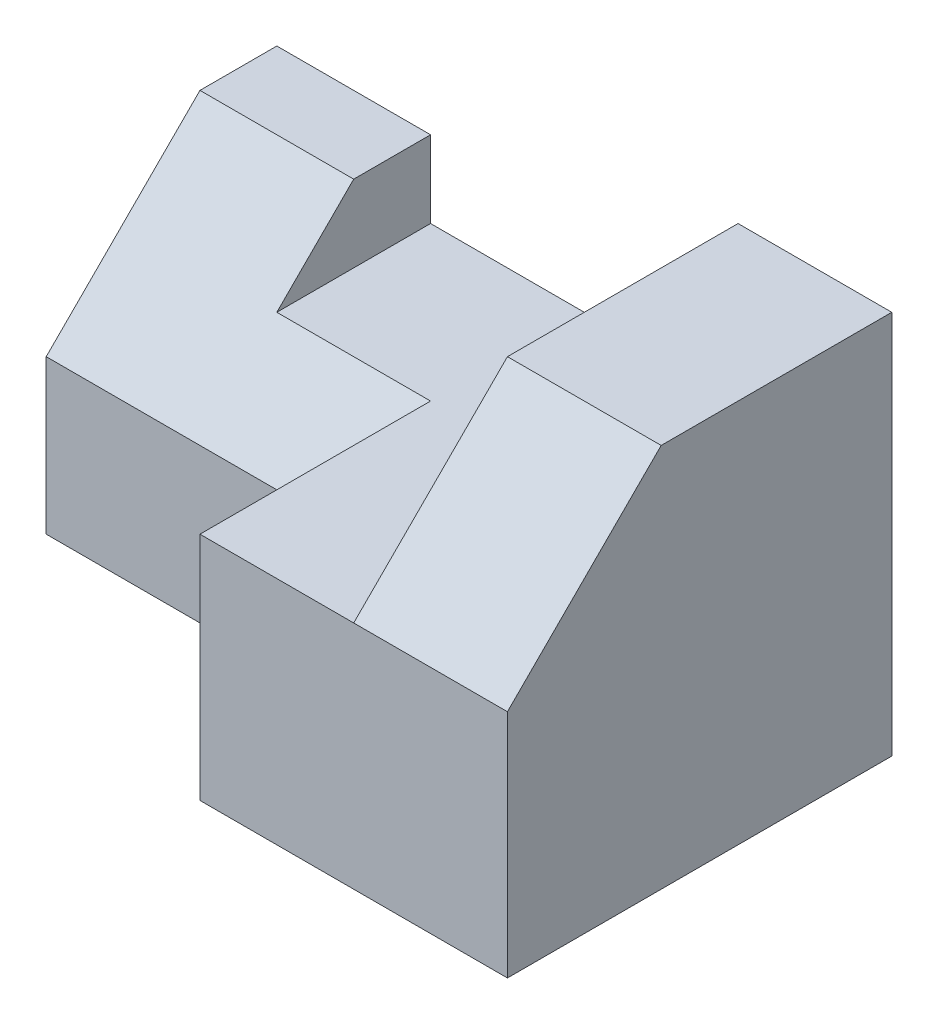
from build123d import *

# Parameters (mm, degrees)
SKETCH1_W           = 80
SKETCH1_H           = 50
BOSS_EXTRUDE1_DEPTH = 30
SKETCH2_W           = 40
SKETCH2_H           = 20
CUT_EXTRUDE1_DEPTH  = 30
SKETCH3_W           = 20
SKETCH3_H           = 50
BOSS_EXTRUDE2_DEPTH = 20
CUT_EXTRUDE2_DEPTH  = 20
CUT_EXTRUDE4_DEPTH  = 40
BOSS_EXTRUDE3_DEPTH = 20


with BuildPart() as part:
    # Sketch1 → Boss-Extrude1 (new body)
    with BuildSketch(Plane(origin=(0, 0, 0), x_dir=(1, 0, 0), z_dir=(0, 1, 0))):
        with Locations((40, 25)):
            Rectangle(SKETCH1_W, SKETCH1_H)
    extrude(amount=BOSS_EXTRUDE1_DEPTH)

    # Sketch2 → Cut-Extrude1 (cut)
    with BuildSketch(Plane(origin=(0, 30, 0), x_dir=(1, 0, 0), z_dir=(0, 1, 0))):
        with Locations((20, 10)):
            Rectangle(SKETCH2_W, SKETCH2_H)
    extrude(amount=-CUT_EXTRUDE1_DEPTH, mode=Mode.SUBTRACT)

    # Sketch3 → Boss-Extrude2 (add)
    with BuildSketch(Plane(origin=(0, 30, 0), x_dir=(1, 0, 0), z_dir=(0, 1, 0))):
        with Locations((70, 25)):
            Rectangle(SKETCH3_W, SKETCH3_H)
    extrude(amount=BOSS_EXTRUDE2_DEPTH)

    # Sketch4 → Cut-Extrude2 (cut)
    with BuildSketch(Plane(origin=(80, 0, 0), x_dir=(0, 0, -1), z_dir=(1, 0, 0))):
        Polygon((20, 50), (0, 30), (0, 50), align=None)
    extrude(amount=-CUT_EXTRUDE2_DEPTH, mode=Mode.SUBTRACT)

    # Sketch5 → Cut-Extrude4 (cut)
    with BuildSketch(Plane.ZY):
        Polygon((-30, 30), (-20, 20), (-20, 30), align=None)
    extrude(amount=-CUT_EXTRUDE4_DEPTH, mode=Mode.SUBTRACT)

    # Sketch6 → Boss-Extrude3 (add)
    with BuildSketch(Plane.ZY):
        Polygon((-50, 30), (-50, 40), (-40, 40), (-30, 30), (-20, 20), (-20, 0), (-50, 0), align=None)
    extrude(amount=-BOSS_EXTRUDE3_DEPTH)


solid = part.part
